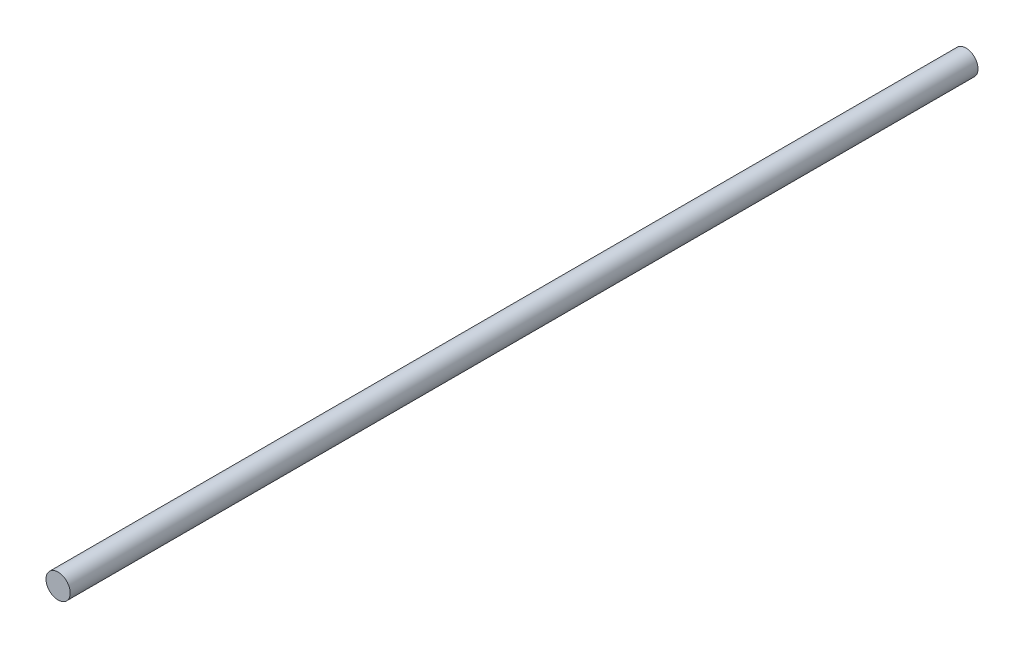
from build123d import *

# Parameters (mm, degrees)
ESQUISSE1_W = 4
ESQUISSE1_H = 300


with BuildPart() as part:
    # Esquisse1 → Révolution1 (revolve)
    with BuildSketch(Plane(origin=(0, 0, 0), x_dir=(1, 0, 0), z_dir=(0, 1, 0))):
        with Locations((2, 0)):
            Rectangle(ESQUISSE1_W, ESQUISSE1_H)
    revolve(axis=Axis((0, 0, -150), (0, 0, 1)))


solid = part.part
